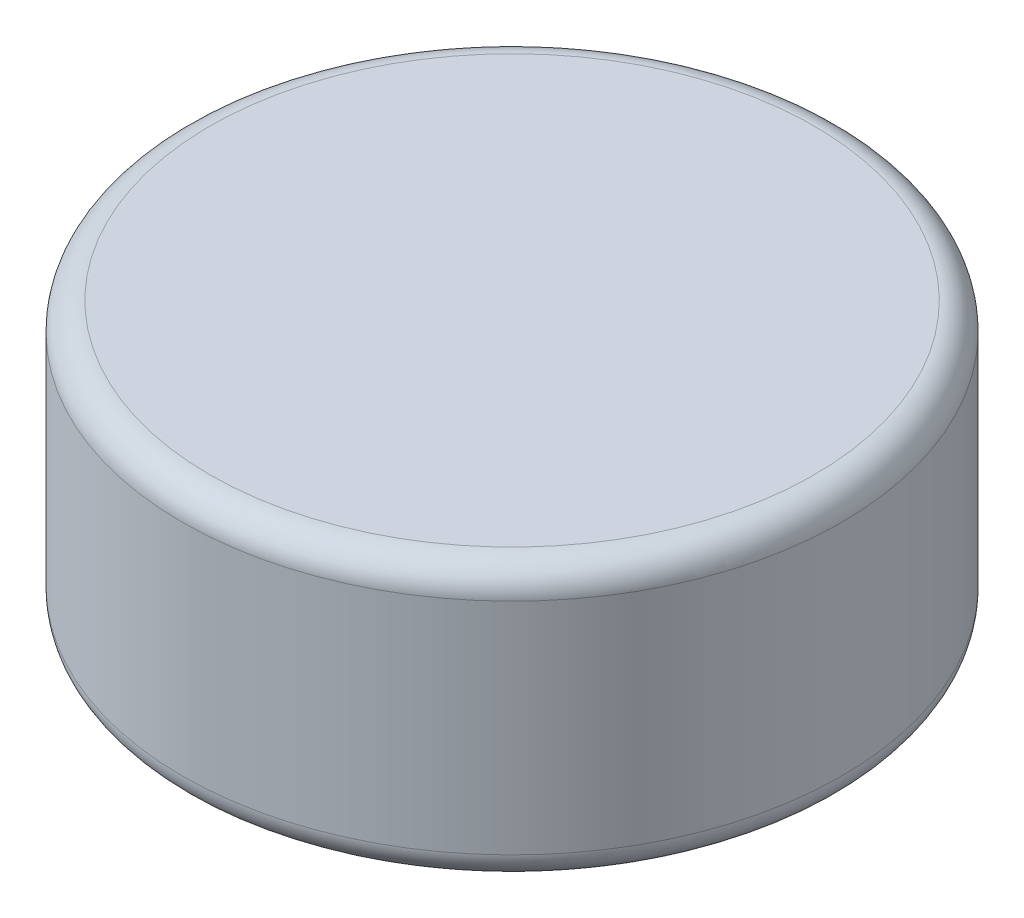
from build123d import *

# Parameters (mm, degrees)
SKETCH1_R           = 3
BOSS_EXTRUDE1_DEPTH = 1.25
FILLET1_R           = 0.25


with BuildPart() as part:
    # Sketch1 → Boss-Extrude1 (new body, symmetric)
    with BuildSketch(Plane(origin=(0, 0, 0), x_dir=(1, 0, 0), z_dir=(0, 1, 0))):
        Circle(SKETCH1_R)
    extrude(amount=BOSS_EXTRUDE1_DEPTH, both=True)

    # Fillet1
    fillet1_edges = [part.edges().sort_by_distance(p)[0] for p in [
        (-3, -1.25, 0),
        (-3, 1.25, 0),
    ]]
    fillet(fillet1_edges, radius=FILLET1_R)


solid = part.part
